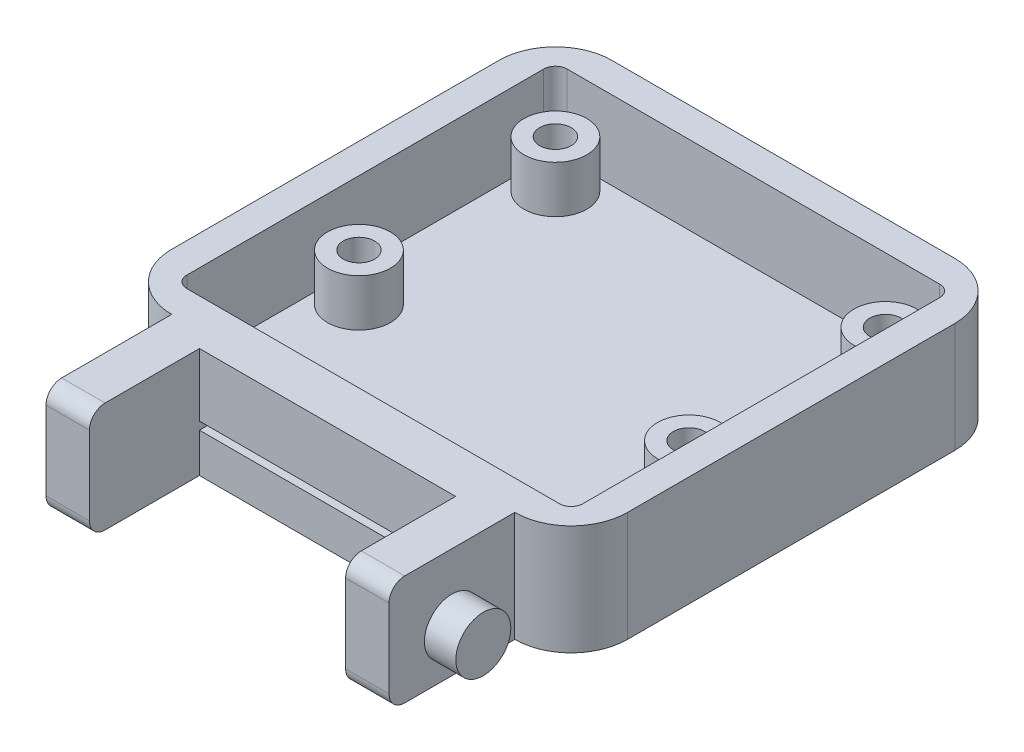
from build123d import *

# Parameters (mm, degrees)
BOSS_EXTRUDE1_DEPTH   = 7
SKETCH2_R             = 2
CUT_EXTRUDE2_DEPTH    = 5
SKETCH3_R             = 2
CUT_EXTRUDE3_DEPTH    = 2
SKETCH4_W             = 16.3
SKETCH4_H             = 0.5
CUT_EXTRUDE4_DEPTH    = 2
F_2_0MM_DOWEL_HOLE1_D = 2
SKETCH8_W             = 21.826362025
SKETCH8_H             = 7
SKETCH8_W_2           = 16.3
SKETCH8_H_2           = 0.5
BOSS_EXTRUDE2_DEPTH   = 8
SKETCH9_R             = 1.75
BOSS_EXTRUDE3_DEPTH   = 2
LPATTERN4_COUNT       = 2
LPATTERN4_PITCH       = 23.75
SKETCH10_W            = 16.3
SKETCH10_H            = 7
CUT_EXTRUDE5_DEPTH    = 7
FILLET1_R             = 1


with BuildPart() as part:
    # Sketch1 → Boss-Extrude1 (new body)
    with BuildSketch(Plane(origin=(0, 0, 0), x_dir=(1, 0, 0), z_dir=(0, 1, 0))):
        with BuildLine():
            Line((-12.921525848, 14.392842997), (-12.921525848, -6.433519028))
            ThreePointArc((-12.921525848, -6.433519028), (-11.87097089, -8.969783057), (-9.334706861, -10.020338016))
            Line((-9.334706861, -10.020338016), (12.491655164, -10.020338016))
            ThreePointArc((12.491655164, -10.020338016), (15.027919193, -8.969783057), (16.078474152, -6.433519028))
            Line((16.078474152, -6.433519028), (16.078474152, 14.392842997))
            ThreePointArc((16.078474152, 14.392842997), (15.027919193, 16.929107026), (12.491655164, 17.979661984))
            Line((12.491655164, 17.979661984), (-9.334706861, 17.979661984))
            ThreePointArc((-9.334706861, 17.979661984), (-11.87097089, 16.929107026), (-12.921525848, 14.392842997))
        make_face()
    extrude(amount=BOSS_EXTRUDE1_DEPTH)

    # Sketch2 → Cut-Extrude2 (cut)
    with BuildSketch(Plane(origin=(0, 7, 0), x_dir=(1, 0, 0), z_dir=(0, 1, 0))):
        with BuildLine():
            Line((-10.27448552, 16.079661984), (13.431433823, 16.079661984))
            ThreePointArc((13.431433823, 16.079661984), (13.959671105, 15.860858938), (14.178474152, 15.332621656))
            Line((14.178474152, 15.332621656), (14.178474152, -7.373297687))
            ThreePointArc((14.178474152, -7.373297687), (13.959671105, -7.901534969), (13.431433823, -8.120338016))
            Line((13.431433823, -8.120338016), (-10.27448552, -8.120338016))
            ThreePointArc((-10.27448552, -8.120338016), (-10.802722802, -7.901534969), (-11.021525848, -7.373297687))
            Line((-11.021525848, -7.373297687), (-11.021525848, 15.332621656))
            ThreePointArc((-11.021525848, 15.332621656), (-10.802722802, 15.860858938), (-10.27448552, 16.079661984))
        make_face()
        with Locations((-8.921525848, 13.979661984)):
            Circle(SKETCH2_R, mode=Mode.SUBTRACT)
        with Locations((12.078474152, 13.979661984)):
            Circle(SKETCH2_R, mode=Mode.SUBTRACT)
        with Locations((-8.921525848, 1.479661984)):
            Circle(SKETCH2_R, mode=Mode.SUBTRACT)
        with Locations((12.078474152, 1.479661984)):
            Circle(SKETCH2_R, mode=Mode.SUBTRACT)
    extrude(amount=-CUT_EXTRUDE2_DEPTH, mode=Mode.SUBTRACT)

    # Sketch3 → Cut-Extrude3 (cut)
    with BuildSketch(Plane(origin=(0, 7, 0), x_dir=(1, 0, 0), z_dir=(0, 1, 0))):
        with Locations((12.078474152, 13.979661984)):
            Circle(SKETCH3_R)
        with Locations((12.078474152, 1.479661984)):
            Circle(SKETCH3_R)
        with Locations((-8.921525848, 13.979661984)):
            Circle(SKETCH3_R)
        with Locations((-8.921525848, 1.479661984)):
            Circle(SKETCH3_R)
    extrude(amount=-CUT_EXTRUDE3_DEPTH, mode=Mode.SUBTRACT)

    # Sketch4 → Cut-Extrude4 (cut)
    with BuildSketch(Plane.XY.offset(10.020338016)):
        with Locations((1.578474152, 2.75)):
            Rectangle(SKETCH4_W, SKETCH4_H)
    extrude(amount=-CUT_EXTRUDE4_DEPTH, mode=Mode.SUBTRACT)

    # Ø2.0mm Dowel Hole1 (through all)
    with Locations(Plane(origin=(0, 5, 0), x_dir=(1, 0, 0), z_dir=(0, 1, 0))):
        with Locations((12.078474152, 1.479661984), (12.078474152, 13.979661984), (-8.921525848, 1.479661984), (-8.921525848, 13.979661984)):
            Hole(F_2_0MM_DOWEL_HOLE1_D / 2)

    # Sketch8 → Boss-Extrude2 (add)
    with BuildSketch(Plane.XY.offset(10.020338016)):
        with Locations((1.578474152, 3.5)):
            Rectangle(SKETCH8_W, SKETCH8_H)
        with Locations((1.578474152, 2.75)):
            Rectangle(SKETCH8_W_2, SKETCH8_H_2, mode=Mode.SUBTRACT)
    extrude(amount=BOSS_EXTRUDE2_DEPTH)

    # Sketch9 → Boss-Extrude3 (add)
    with BuildSketch(Plane(origin=(12.491655164, 0, 0), x_dir=(0, 0, -1), z_dir=(1, 0, 0))):
        with Locations((-14.020338016, 2.75)):
            Circle(SKETCH9_R)
    boss_extrude3 = extrude(amount=BOSS_EXTRUDE3_DEPTH)

    # LPattern4: Boss-Extrude3 ×2
    with Locations(*[(-i * LPATTERN4_PITCH, 0, 0) for i in range(1, LPATTERN4_COUNT)]):
        add(boss_extrude3)

    # Sketch10 → Cut-Extrude5 (cut)
    with BuildSketch(Plane.XY.offset(18.020338016)):
        with Locations((1.578474152, 3.5)):
            Rectangle(SKETCH10_W, SKETCH10_H)
    extrude(amount=-CUT_EXTRUDE5_DEPTH, mode=Mode.SUBTRACT)

    # Fillet1
    fillet1_edges = [part.edges().sort_by_distance(p)[0] for p in [
        (-7.953116354, 0, 18.020338016),
        (11.110064658, 7, 18.020338016),
        (11.110064658, 0, 18.020338016),
        (-7.953116354, 7, 18.020338016),
    ]]
    fillet(fillet1_edges, radius=FILLET1_R)


solid = part.part
